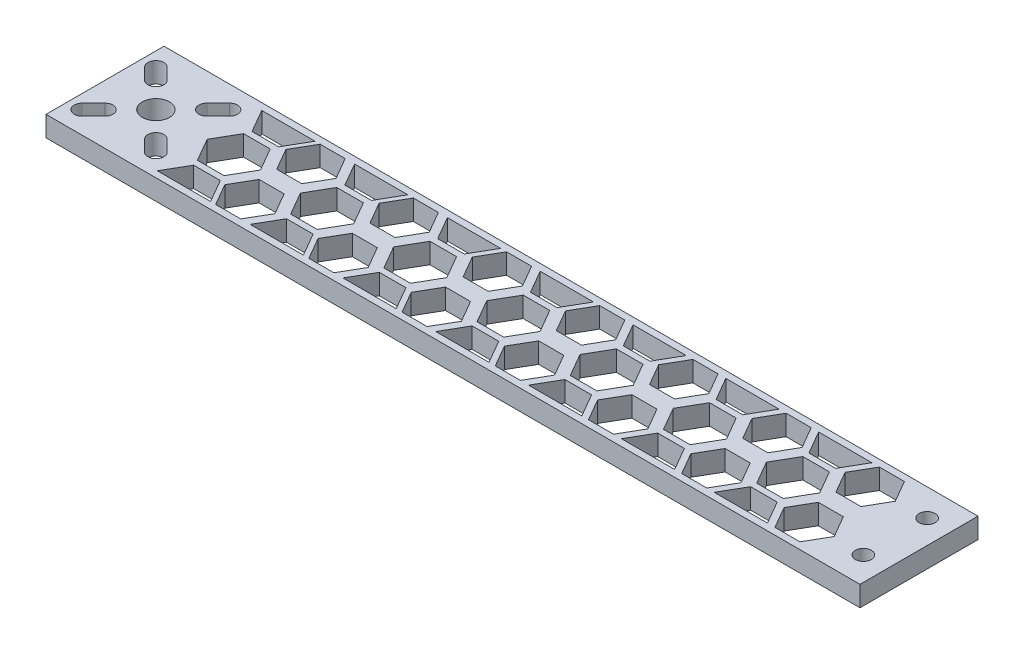
from build123d import *

# Parameters (mm, degrees)
SKETCH1_W           = 152.4
SKETCH1_H           = 22.098
SKETCH1_R           = 1.5
BOSS_EXTRUDE1_DEPTH = 3.81
CUT_EXTRUDE1_DEPTH  = 3.81
CUT_EXTRUDE2_REACH  = 5.81
SKETCH3_R           = 2.54


with BuildPart() as part:
    # Sketch1 → Boss-Extrude1 (new body)
    with BuildSketch(Plane(origin=(0, 0, 0), x_dir=(1, 0, 0), z_dir=(0, 1, 0))):
        Rectangle(SKETCH1_W, SKETCH1_H)
        with Locations((71.755, 5.969)):
            Circle(SKETCH1_R, mode=Mode.SUBTRACT)
        with Locations((71.755, -5.969)):
            Circle(SKETCH1_R, mode=Mode.SUBTRACT)
    extrude(amount=BOSS_EXTRUDE1_DEPTH)

    # Sketch2 → Cut-Extrude1 (cut)
    with BuildSketch(Plane(origin=(0, 3.81, 0), x_dir=(1, 0, 0), z_dir=(0, 1, 0))):
        Polygon((63.693648506, -9.779), (66.04, -5.715), (63.693648506, -1.651), (59.000945518, -1.651), (56.654594024, -5.715), (59.000945518, -9.779), align=None)
        Polygon((63.693648506, 1.651), (66.04, 5.715), (63.693648506, 9.779), (59.000945518, 9.779), (56.654594024, 5.715), (59.000945518, 1.651), align=None)
        Polygon((46.242659269, -9.779), (48.589010763, -5.715), (46.242659269, -1.651), (41.549956282, -1.651), (39.203604788, -5.715), (41.549956282, -9.779), align=None)
        Polygon((46.242659269, 1.651), (48.589010763, 5.715), (46.242659269, 9.779), (41.549956282, 9.779), (39.203604788, 5.715), (41.549956282, 1.651), align=None)
        Polygon((37.66381162, -4.318), (40.156810082, 0), (37.66381162, 4.318), (32.677814695, 4.318), (30.184816233, 0), (32.677814695, -4.318), align=None)
        Polygon((55.114800856, -4.318), (57.607799318, 0), (55.114800856, 4.318), (50.128803931, 4.318), (47.635805469, 0), (50.128803931, -4.318), align=None)
        Polygon((28.791670033, -9.779), (31.138021527, -5.715), (28.791670033, -1.651), (24.098967045, -1.651), (21.752615551, -5.715), (24.098967045, -9.779), align=None)
        Polygon((28.791670033, 1.651), (31.138021527, 5.715), (28.791670033, 9.779), (24.098967045, 9.779), (21.752615551, 5.715), (24.098967045, 1.651), align=None)
        Polygon((20.212822383, -4.318), (22.705820845, 0), (20.212822383, 4.318), (15.226825458, 4.318), (12.733826996, 0), (15.226825458, -4.318), align=None)
        Polygon((11.340680796, -9.779), (13.68703229, -5.715), (11.340680796, -1.651), (6.647977808, -1.651), (4.301626314, -5.715), (6.647977808, -9.779), align=None)
        Polygon((11.340680796, 1.651), (13.68703229, 5.715), (11.340680796, 9.779), (6.647977808, 9.779), (4.301626314, 5.715), (6.647977808, 1.651), align=None)
        Polygon((2.761833147, -4.318), (5.254831609, 0), (2.761833147, 4.318), (-2.224163778, 4.318), (-4.717162241, 0), (-2.224163778, -4.318), align=None)
        Polygon((-6.11030844, -9.779), (-3.763956946, -5.715), (-6.11030844, -1.651), (-10.803011428, -1.651), (-13.149362922, -5.715), (-10.803011428, -9.779), align=None)
        Polygon((-6.11030844, 1.651), (-3.763956946, 5.715), (-6.11030844, 9.779), (-10.803011428, 9.779), (-13.149362922, 5.715), (-10.803011428, 1.651), align=None)
        Polygon((-14.68915609, -4.318), (-12.196157628, 0), (-14.68915609, 4.318), (-19.675153015, 4.318), (-22.168151477, 0), (-19.675153015, -4.318), align=None)
        Polygon((-23.561297677, -9.779), (-21.214946183, -5.715), (-23.561297677, -1.651), (-28.254000665, -1.651), (-30.600352159, -5.715), (-28.254000665, -9.779), align=None)
        Polygon((-23.561297677, 1.651), (-21.214946183, 5.715), (-23.561297677, 9.779), (-28.254000665, 9.779), (-30.600352159, 5.715), (-28.254000665, 1.651), align=None)
        Polygon((-32.140145327, -4.318), (-29.647146864, 0), (-32.140145327, 4.318), (-37.126142251, 4.318), (-39.619140714, 0), (-37.126142251, -4.318), align=None)
        Polygon((-41.012286913, -9.779), (-38.665935419, -5.715), (-41.012286913, -1.651), (-45.704989901, -1.651), (-48.051341395, -5.715), (-45.704989901, -9.779), align=None)
        Polygon((-41.012286913, 1.651), (-38.665935419, 5.715), (-41.012286913, 9.779), (-45.704989901, 9.779), (-48.051341395, 5.715), (-45.704989901, 1.651), align=None)
        Polygon((-49.591134563, -4.318), (-47.098136101, 0), (-49.591134563, 4.318), (-54.577131488, 4.318), (-57.07012995, 0), (-54.577131488, -4.318), align=None)
        Polygon((57.607799318, 9.779), (47.635805469, 9.779), (50.128803931, 5.461), (55.114800856, 5.461), align=None)
        Polygon((55.114800856, -5.461), (57.607799318, -9.779), (47.635805469, -9.779), (50.128803931, -5.461), align=None)
        Polygon((40.230133566, 9.779), (30.258139717, 9.779), (32.751138179, 5.461), (37.737135104, 5.461), align=None)
        Polygon((37.737135104, -5.461), (40.230133566, -9.779), (30.258139717, -9.779), (32.751138179, -5.461), align=None)
        Polygon((22.852467814, 9.779), (12.880473964, 9.779), (15.373472427, 5.461), (20.359469351, 5.461), align=None)
        Polygon((20.359469351, -5.461), (22.852467814, -9.779), (12.880473964, -9.779), (15.373472427, -5.461), align=None)
        Polygon((5.474802061, 9.779), (-4.497191788, 9.779), (-2.004193326, 5.461), (2.981803599, 5.461), align=None)
        Polygon((2.981803599, -5.461), (5.474802061, -9.779), (-4.497191788, -9.779), (-2.004193326, -5.461), align=None)
        Polygon((-11.902863691, 9.779), (-21.87485754, 9.779), (-19.381859078, 5.461), (-14.395862153, 5.461), align=None)
        Polygon((-14.395862153, -5.461), (-11.902863691, -9.779), (-21.87485754, -9.779), (-19.381859078, -5.461), align=None)
        Polygon((-29.280529443, 9.779), (-39.252523293, 9.779), (-36.75952483, 5.461), (-31.773527906, 5.461), align=None)
        Polygon((-31.773527906, -5.461), (-29.280529443, -9.779), (-39.252523293, -9.779), (-36.75952483, -5.461), align=None)
        Polygon((-46.658195196, 9.779), (-56.630189045, 9.779), (-54.137190583, 5.461), (-49.151193658, 5.461), align=None)
        Polygon((-49.151193658, -5.461), (-46.658195196, -9.779), (-56.630189045, -9.779), (-54.137190583, -5.461), align=None)
    extrude(amount=-CUT_EXTRUDE1_DEPTH, mode=Mode.SUBTRACT)

    # Sketch3 → Cut-Extrude2 (cut, up to next)
    with BuildSketch(Plane(origin=(0, 3.81, 0), x_dir=(1, 0, 0), z_dir=(0, 1, 0)), mode=Mode.PRIVATE) as cut_extrude2_sk1:
        with Locations((-66.675, 0)):
            Circle(SKETCH3_R)
    cut_extrude2_tool1 = extrude(cut_extrude2_sk1.sketch, amount=-CUT_EXTRUDE2_REACH, mode=Mode.PRIVATE) & part.part
    add(cut_extrude2_tool1.solids().sort_by_distance((-66.675, 3.81, 0))[0], mode=Mode.SUBTRACT)
    # Sketch3 → Cut-Extrude2 (cut, up to next)
    with BuildSketch(Plane(origin=(0, 3.81, 0), x_dir=(1, 0, 0), z_dir=(0, 1, 0)), mode=Mode.PRIVATE) as cut_extrude2_sk2:
        with BuildLine():
            Line((-74.629951288, -5.833630945), (-72.508630945, -3.712310601))
            ThreePointArc((-72.508630945, -3.712310601), (-70.387310601, -3.712310601), (-70.387310601, -5.833630945))
            Line((-70.387310601, -5.833630945), (-72.508630945, -7.954951288))
            ThreePointArc((-72.508630945, -7.954951288), (-74.629951288, -7.954951288), (-74.629951288, -5.833630945))
        make_face()
    cut_extrude2_tool2 = extrude(cut_extrude2_sk2.sketch, amount=-CUT_EXTRUDE2_REACH, mode=Mode.PRIVATE) & part.part
    add(cut_extrude2_tool2.solids().sort_by_distance((-72.508631, 3.81, 5.833631))[0], mode=Mode.SUBTRACT)
    # Sketch3 → Cut-Extrude2 (cut, up to next)
    with BuildSketch(Plane(origin=(0, 3.81, 0), x_dir=(1, 0, 0), z_dir=(0, 1, 0)), mode=Mode.PRIVATE) as cut_extrude2_sk3:
        with BuildLine():
            Line((-74.629951288, 5.833630945), (-72.508630945, 3.712310601))
            ThreePointArc((-72.508630945, 3.712310601), (-70.387310601, 3.712310601), (-70.387310601, 5.833630945))
            Line((-70.387310601, 5.833630945), (-72.508630945, 7.954951288))
            ThreePointArc((-72.508630945, 7.954951288), (-74.629951288, 7.954951288), (-74.629951288, 5.833630945))
        make_face()
    cut_extrude2_tool3 = extrude(cut_extrude2_sk3.sketch, amount=-CUT_EXTRUDE2_REACH, mode=Mode.PRIVATE) & part.part
    add(cut_extrude2_tool3.solids().sort_by_distance((-72.508631, 3.81, -5.833631))[0], mode=Mode.SUBTRACT)
    # Sketch3 → Cut-Extrude2 (cut, up to next)
    with BuildSketch(Plane(origin=(0, 3.81, 0), x_dir=(1, 0, 0), z_dir=(0, 1, 0)), mode=Mode.PRIVATE) as cut_extrude2_sk4:
        with BuildLine():
            Line((-60.841369055, 7.954951288), (-62.962689399, 5.833630945))
            ThreePointArc((-62.962689399, 5.833630945), (-62.962689399, 3.712310601), (-60.841369055, 3.712310601))
            Line((-60.841369055, 3.712310601), (-58.720048712, 5.833630945))
            ThreePointArc((-58.720048712, 5.833630945), (-58.720048712, 7.954951288), (-60.841369055, 7.954951288))
        make_face()
    cut_extrude2_tool4 = extrude(cut_extrude2_sk4.sketch, amount=-CUT_EXTRUDE2_REACH, mode=Mode.PRIVATE) & part.part
    add(cut_extrude2_tool4.solids().sort_by_distance((-60.841369, 3.81, -5.833631))[0], mode=Mode.SUBTRACT)
    # Sketch3 → Cut-Extrude2 (cut, up to next)
    with BuildSketch(Plane(origin=(0, 3.81, 0), x_dir=(1, 0, 0), z_dir=(0, 1, 0)), mode=Mode.PRIVATE) as cut_extrude2_sk5:
        with BuildLine():
            Line((-58.720048712, -5.833630945), (-60.841369055, -3.712310601))
            ThreePointArc((-60.841369055, -3.712310601), (-62.962689399, -3.712310601), (-62.962689399, -5.833630945))
            Line((-62.962689399, -5.833630945), (-60.841369055, -7.954951288))
            ThreePointArc((-60.841369055, -7.954951288), (-58.720048712, -7.954951288), (-58.720048712, -5.833630945))
        make_face()
    cut_extrude2_tool5 = extrude(cut_extrude2_sk5.sketch, amount=-CUT_EXTRUDE2_REACH, mode=Mode.PRIVATE) & part.part
    add(cut_extrude2_tool5.solids().sort_by_distance((-60.841369, 3.81, 5.833631))[0], mode=Mode.SUBTRACT)


solid = part.part
